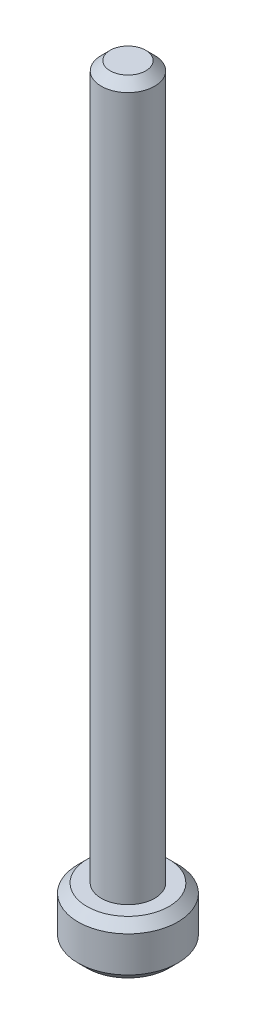
from build123d import *

# Parameters (mm, degrees)
SKETCH1_R           = 2.8
BOSS_EXTRUDE1_DEPTH = 1.5
SKETCH2_R           = 1.5
BOSS_EXTRUDE2_DEPTH = 40
CHAMFER1_SIZE       = 0.5
CHAMFER2_SIZE       = 0.5


with BuildPart() as part:
    # Sketch1 → Boss-Extrude1 (new body, symmetric)
    with BuildSketch(Plane(origin=(0, 0, 0), x_dir=(1, 0, 0), z_dir=(0, 1, 0))):
        Circle(SKETCH1_R)
    extrude(amount=BOSS_EXTRUDE1_DEPTH, both=True)

    # Sketch2 → Boss-Extrude2 (add)
    with BuildSketch(Plane(origin=(0, 1.5, 0), x_dir=(1, 0, 0), z_dir=(0, 1, 0))):
        Circle(SKETCH2_R)
    extrude(amount=BOSS_EXTRUDE2_DEPTH)

    # Chamfer1
    chamfer1_edges = [part.edges().sort_by_distance(p)[0] for p in [
        (-1.5, 41.5, 0),
    ]]
    chamfer(chamfer1_edges, length=CHAMFER1_SIZE)

    # Chamfer2
    chamfer2_edges = [part.edges().sort_by_distance(p)[0] for p in [
        (-2.8, -1.5, 0),
        (-2.8, 1.5, 0),
    ]]
    chamfer(chamfer2_edges, length=CHAMFER2_SIZE)


solid = part.part
